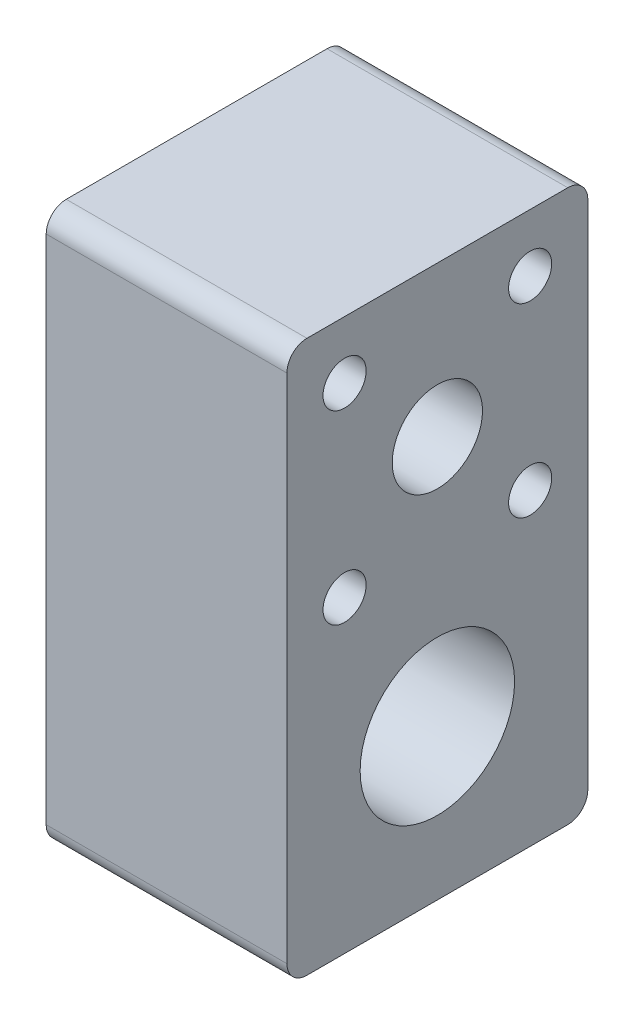
from build123d import *

# Parameters (mm, degrees)
SKETCH1_R           = 7.7
SKETCH1_R_2         = 4.5
BOSS_EXTRUDE1_DEPTH = 12
SKETCH2_R           = 2.15
CUT_EXTRUDE1_DEPTH  = 25
FILLET1_R           = 2


with BuildPart() as part:
    # Sketch1 → Boss-Extrude1 (new body, symmetric)
    with BuildSketch(Plane(origin=(0, 0, 0), x_dir=(0, 0, -1), z_dir=(1, 0, 0))):
        Polygon((15, 10), (15, -15), (-15, -15), (-15, 10), (-15, 40), (15, 40), align=None)
        Circle(SKETCH1_R, mode=Mode.SUBTRACT)
        with Locations((0, 25)):
            Circle(SKETCH1_R_2, mode=Mode.SUBTRACT)
    extrude(amount=BOSS_EXTRUDE1_DEPTH, both=True)

    # Sketch2 → Cut-Extrude1 (cut, through all)
    with BuildSketch(Plane(origin=(12, 0, 0), x_dir=(0, 0, -1), z_dir=(1, 0, 0))):
        with Locations((-9.25, 34.25)):
            Circle(SKETCH2_R)
        with Locations((-9.25, 15.75)):
            Circle(SKETCH2_R)
        with Locations((9.25, 34.25)):
            Circle(SKETCH2_R)
        with Locations((9.25, 15.75)):
            Circle(SKETCH2_R)
    extrude(amount=-CUT_EXTRUDE1_DEPTH, mode=Mode.SUBTRACT)

    # Fillet1
    fillet1_edges = [part.edges().sort_by_distance(p)[0] for p in [
        (0, 40, 15),
        (0, 40, -15),
        (0, -15, -15),
        (0, -15, 15),
    ]]
    fillet(fillet1_edges, radius=FILLET1_R)


solid = part.part
